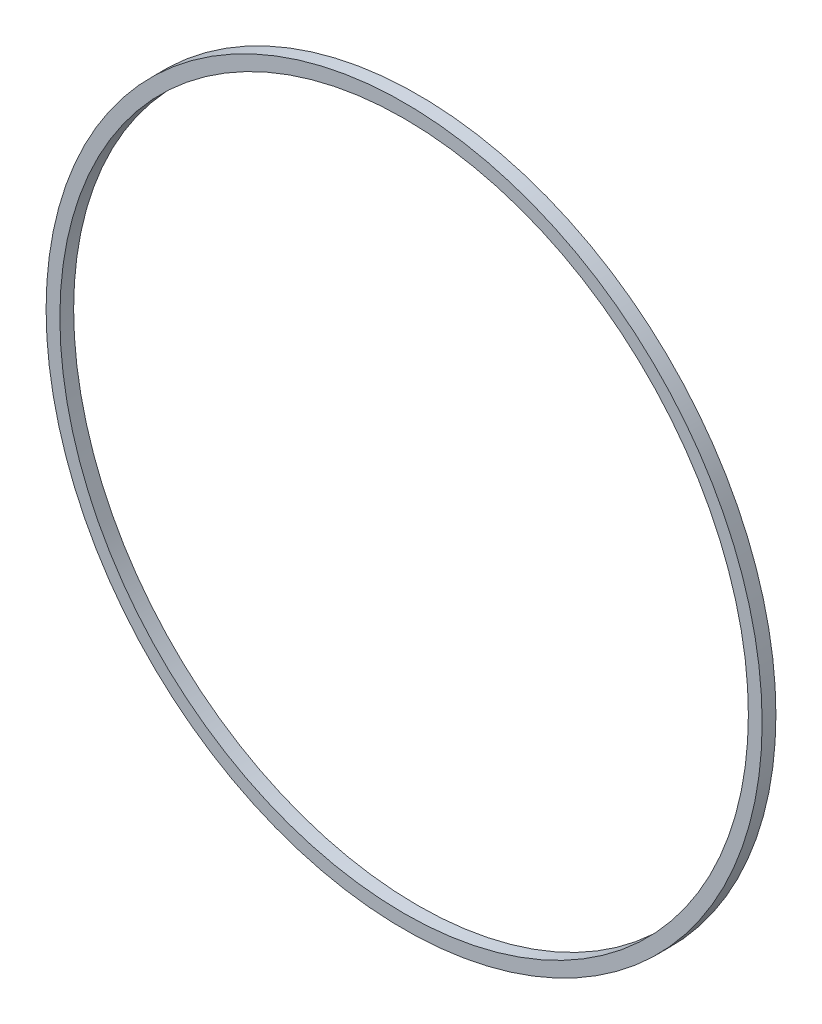
from build123d import *

# Parameters (mm, degrees)
SKETCH1_R           = 52
SKETCH1_R_2         = 50
BOSS_EXTRUDE5_DEPTH = 2


with BuildPart() as part:
    # Sketch1 → Boss-Extrude5 (new body)
    with BuildSketch(Plane.XY):
        with Locations((-19.870639263, -20.903178587)):
            Circle(SKETCH1_R)
        with Locations((-19.870639263, -20.903178587)):
            Circle(SKETCH1_R_2, mode=Mode.SUBTRACT)
    extrude(amount=BOSS_EXTRUDE5_DEPTH)


solid = part.part
